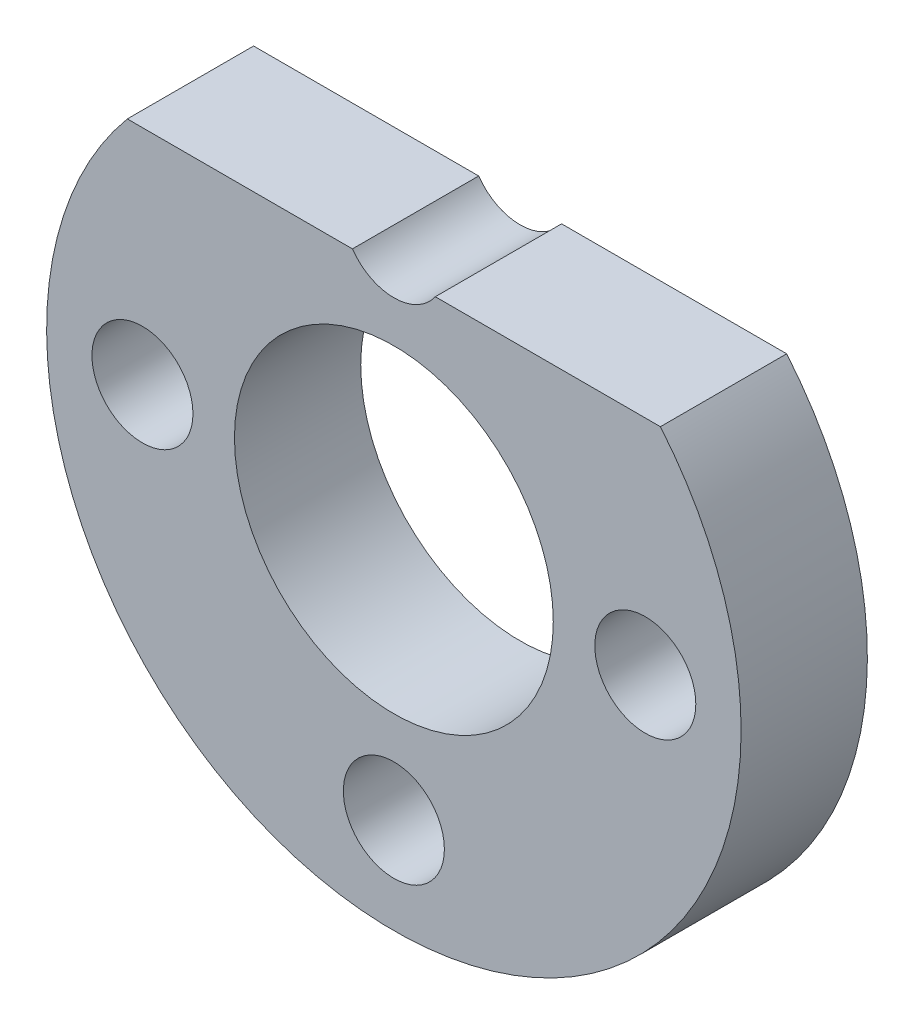
from build123d import *

# Parameters (mm, degrees)
RESSALTO_EXTRUS_O1_DEPTH = 4
ESBO_O2_R                = 5.05
CORTE_EXTRUS_O1_DEPTH    = 4
M3_CLEARANCE_HOLE1_D     = 3.2


with BuildPart() as part:
    # Esboço1 → Ressalto-extrusão1 (new body)
    with BuildSketch(Plane.XY):
        with BuildLine():
            Line((95.202808527, -295.7159332), (112.09037792, -295.7159332))
            ThreePointArc((112.09037792, -295.7159332), (103.646593224, -313.7659332), (95.202808527, -295.7159332))
        make_face()
    extrude(amount=RESSALTO_EXTRUS_O1_DEPTH)

    # Esboço2 → Corte-extrusão1 (cut)
    with BuildSketch(Plane.XY.offset(4)):
        with Locations((103.646593224, -302.7659332)):
            Circle(ESBO_O2_R)
    extrude(amount=-CORTE_EXTRUS_O1_DEPTH, mode=Mode.SUBTRACT)

    # M3 Clearance Hole1 (through all)
    with Locations(Plane.XY.offset(4)):
        with Locations((95.681870132, -302.765933199), (111.611316315, -302.765933199), (103.646593224, -310.730656291), (103.646593224, -294.801210108)):
            Hole(M3_CLEARANCE_HOLE1_D / 2)


solid = part.part
